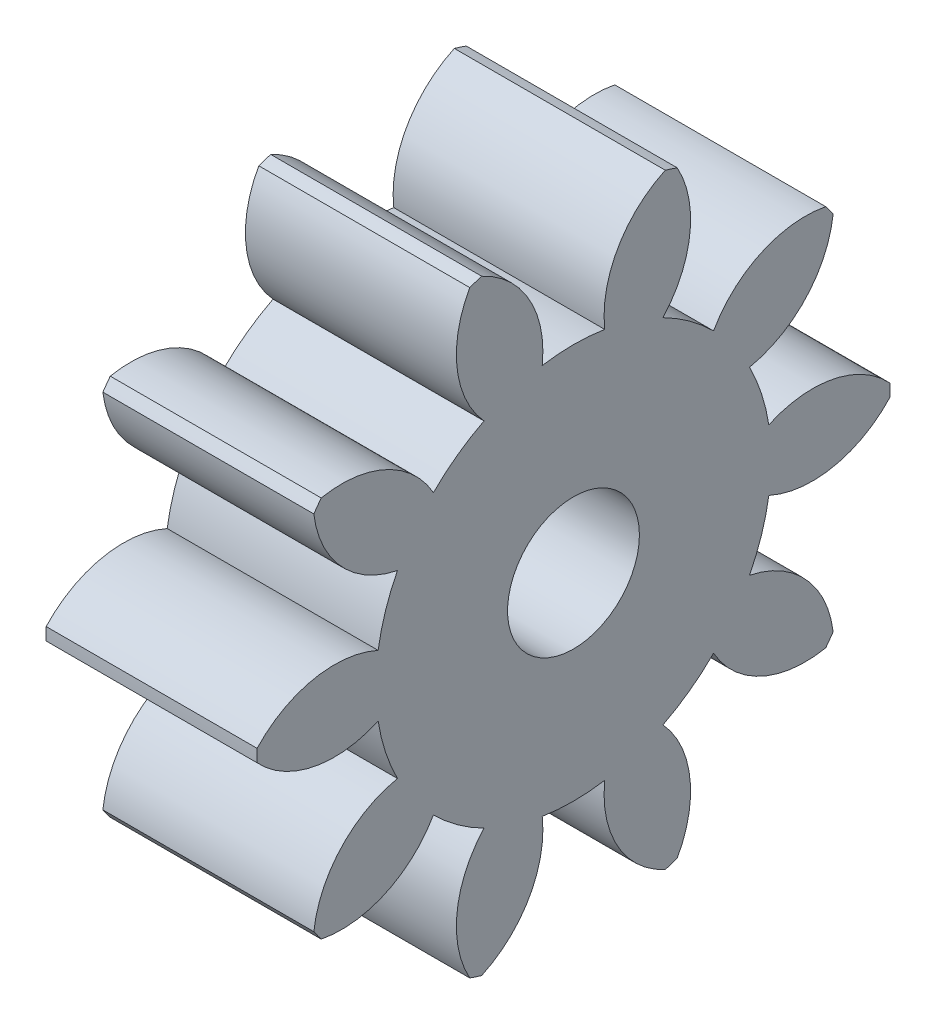
from build123d import *

# Parameters (mm, degrees)
BASPROSKE_W         = 4
BASPROSKE_H         = 6
TOOTHCUT_DEPTH      = 10.38083152
TEETHCUTS_COUNT     = 10
BORSKE_R            = 1
BORE_DEPTH          = 50.0000508
SKETCH_1_R          = 1.25
CUT_EXTRUDE_1_DEPTH = 10


with BuildPart() as part:
    # BasProSke → Base-Revolve (revolve)
    with BuildSketch(Plane(origin=(0, 0, 0), x_dir=(1, 0, 0), z_dir=(0, 1, 0)), mode=Mode.PRIVATE) as base_revolve_sk:
        with Locations((2, 3)):
            Rectangle(BASPROSKE_W, BASPROSKE_H)
    revolve(base_revolve_sk.sketch.rotate(Axis((-10, 0, 0), (1, 0, 0)), 180), axis=Axis((-10, 0, 0), (1, 0, 0)))

    # TooCutSke → ToothCut (cut, through all)
    with BuildSketch(Plane(origin=(0, 0, 0), x_dir=(0, 0, -1), z_dir=(1, 0, 0))):
        with BuildLine():
            ThreePointArc((0.59278292, 3.701838653), (0, 3.749), (-0.59278292, 3.701838653))
            ThreePointArc((-0.59278292, 3.701838653), (-0.846593509, 4.924114224), (-1.775771316, 5.757784417))
            ThreePointArc((-1.775771316, 5.757784417), (0, 6.0254), (1.775771316, 5.757784417))
            ThreePointArc((1.775771316, 5.757784417), (0.846593509, 4.924114224), (0.59278292, 3.701838653))
        make_face()
    toothcut = extrude(amount=TOOTHCUT_DEPTH, mode=Mode.SUBTRACT)

    # TeethCuts: ToothCut ×10 about axis
    teethcuts_axis = Axis((0, 0, 0), (1, 0, 0))
    for i in range(1, TEETHCUTS_COUNT):
        add(toothcut.rotate(teethcuts_axis, i * 360 / TEETHCUTS_COUNT), mode=Mode.SUBTRACT)

    # BorSke → Bore (cut, symmetric)
    with BuildSketch(Plane(origin=(0, 0, 0), x_dir=(0, 0, -1), z_dir=(1, 0, 0))):
        with Locations(Location((0, 0, 0), (0, 0, 180))):
            Circle(BORSKE_R)
    extrude(amount=BORE_DEPTH, both=True, mode=Mode.SUBTRACT)

    # 草图1 → 切除-拉伸1 (cut)
    with BuildSketch(Plane(origin=(4, 0, 0), x_dir=(0, 0, -1), z_dir=(1, 0, 0))):
        Circle(SKETCH_1_R)
    extrude(amount=-CUT_EXTRUDE_1_DEPTH, mode=Mode.SUBTRACT)


solid = part.part
